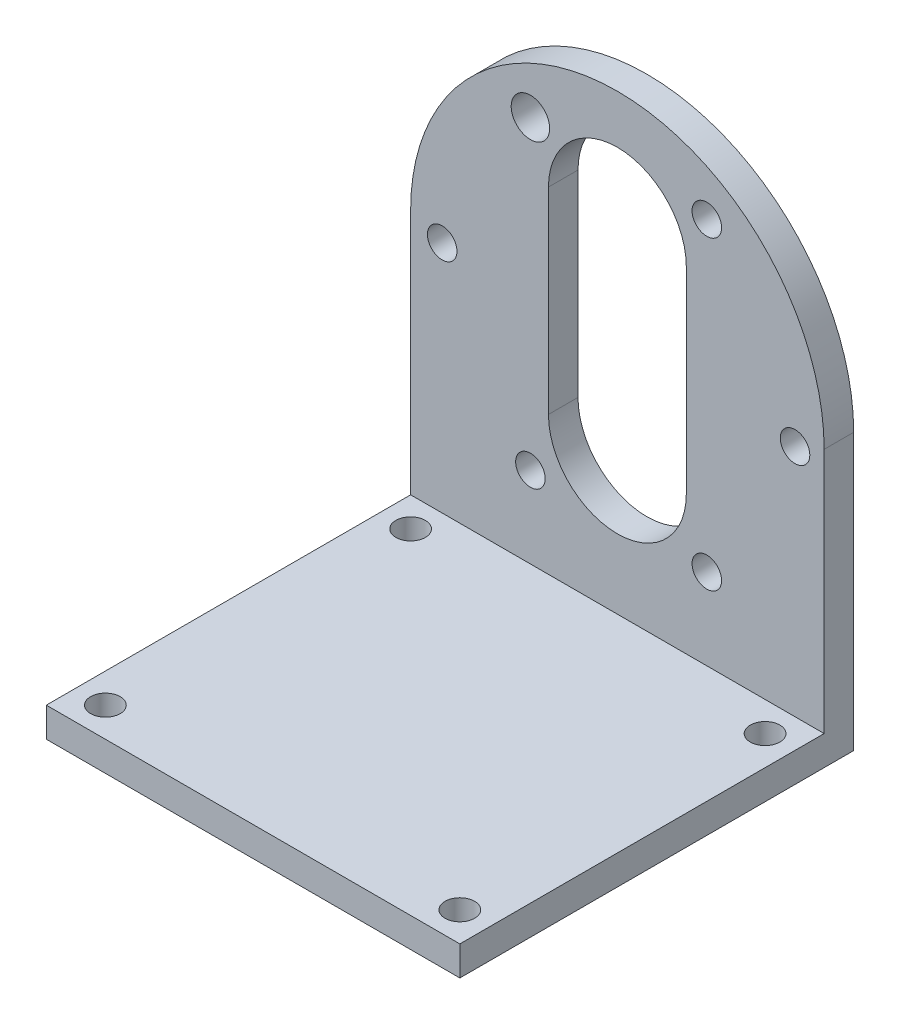
from build123d import *

# Parameters (mm, degrees)
SKETCH_4_W           = 42
SKETCH_4_H           = 40
EXTRUDE_1_DEPTH      = 3
SKETCH_9_W           = 3
SKETCH_9_H           = 25
EXTRUDE_3_DEPTH      = 42
SKETCH_10_R          = 21
EXTRUDE_2_DEPTH      = 3
CUT_EXTRUDE_6_DEPTH  = 3
SKETCH_16_R          = 1.5
CUT_EXTRUDE_7_DEPTH  = 3
SKETCH_14_R          = 1.952306129
CUT_EXTRUDE_8_DEPTH  = 3
SKETCH_17_R          = 1.5
CUT_EXTRUDE_10_DEPTH = 3


with BuildPart() as part:
    # 草图4 → 凸台-拉伸1 (new body)
    with BuildSketch(Plane(origin=(0, 0, 0), x_dir=(1, 0, 0), z_dir=(0, 1, 0))):
        with Locations((0, -1)):
            Rectangle(SKETCH_4_W, SKETCH_4_H)
    extrude(amount=EXTRUDE_1_DEPTH)

    # 草图9 → 拉伸-薄壁3 (add)
    with BuildSketch(Plane.ZY.offset(21)):
        with Locations((-17.5, 15.5)):
            Rectangle(SKETCH_9_W, SKETCH_9_H)
    extrude(amount=-EXTRUDE_3_DEPTH)

    # 草图10 → 凸台-拉伸2 (add)
    with BuildSketch(Plane.XY.offset(-16)):
        with Locations((0, 28)):
            Circle(SKETCH_10_R)
    extrude(amount=-EXTRUDE_2_DEPTH)

    # 草图11 → 切除-拉伸6 (cut)
    with BuildSketch(Plane.XY.offset(-16)):
        with BuildLine():
            Line((-7, 37.068273953), (-7, 17.068273953))
            ThreePointArc((-7, 17.068273953), (0, 10.068273953), (7, 17.068273953))
            Line((7, 17.068273953), (7, 37.068273953))
            ThreePointArc((7, 37.068273953), (0, 44.068273953), (-7, 37.068273953))
        make_face()
    extrude(amount=-CUT_EXTRUDE_6_DEPTH, mode=Mode.SUBTRACT)

    # 草图16 → 切除-拉伸7 (cut)
    with BuildSketch(Plane.XY.offset(-16)):
        with Locations((-8.832661919, 42.279402206)):
            Circle(SKETCH_16_R)
        with Locations((-17.791157853, 26.76283209)):
            Circle(SKETCH_16_R)
        with Locations((-8.832661919, 11.246261974)):
            Circle(SKETCH_16_R)
        with Locations((9.084329947, 11.246261974)):
            Circle(SKETCH_16_R)
        with Locations((18.04282588, 26.76283209)):
            Circle(SKETCH_16_R)
        with Locations((9.084329947, 42.279402206)):
            Circle(SKETCH_16_R)
    extrude(amount=-CUT_EXTRUDE_7_DEPTH, mode=Mode.SUBTRACT)

    # 草图14 → 切除-拉伸8 (cut)
    with BuildSketch(Plane.XY.offset(-16)):
        with Locations((-8.832661919, 42.279402206)):
            Circle(SKETCH_14_R)
    extrude(amount=-CUT_EXTRUDE_8_DEPTH, mode=Mode.SUBTRACT)

    # 草图17 → 切除-拉伸10 (cut)
    with BuildSketch(Plane(origin=(0, 3, 0), x_dir=(1, 0, 0), z_dir=(0, 1, 0))):
        with Locations((-18, 13)):
            Circle(SKETCH_17_R)
        with Locations((18, 13)):
            Circle(SKETCH_17_R)
        with Locations((-18, -18)):
            Circle(SKETCH_17_R)
        with Locations((18, -18)):
            Circle(SKETCH_17_R)
    extrude(amount=-CUT_EXTRUDE_10_DEPTH, mode=Mode.SUBTRACT)


solid = part.part
